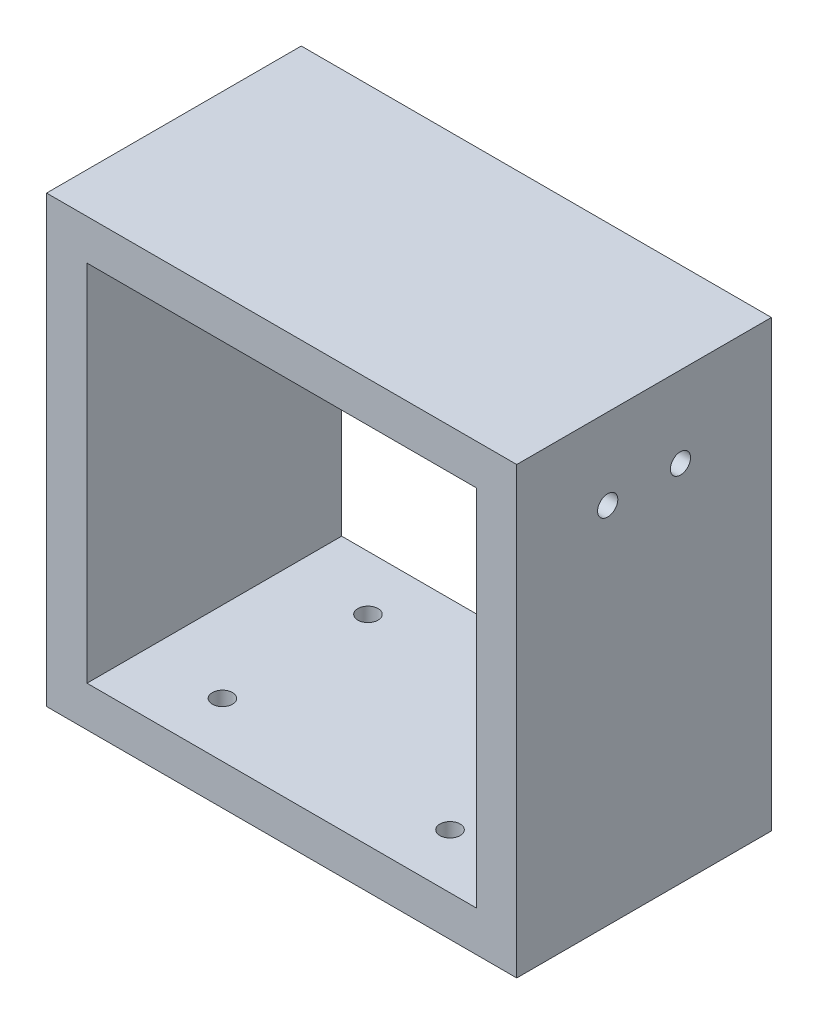
from build123d import *

# Parameters (mm, degrees)
SKETCH_1_W          = 58.15
SKETCH_1_H          = 31.5
EXTRUDE_1_DEPTH     = 55
SKETCH_2_W          = 48.15
SKETCH_2_H          = 45
CUT_EXTRUDE_1_DEPTH = 31.5
SKETCH_4_R          = 1.25
CUT_EXTRUDE_2_DEPTH = 10
SKETCH_5_R          = 1.25
CUT_EXTRUDE_3_DEPTH = 10
SKETCH_6_R          = 1.25
CUT_EXTRUDE_4_DEPTH = 10


with BuildPart() as part:
    # 草图1 → 凸台-拉伸1 (new body)
    with BuildSketch(Plane(origin=(0, 0, 0), x_dir=(1, 0, 0), z_dir=(0, 1, 0))):
        with Locations((29.075, 15.75)):
            Rectangle(SKETCH_1_W, SKETCH_1_H)
    extrude(amount=-EXTRUDE_1_DEPTH)

    # 草图2 → 切除-拉伸1 (cut)
    with BuildSketch(Plane.XY):
        with Locations((29.075, -27.5)):
            Rectangle(SKETCH_2_W, SKETCH_2_H)
    extrude(amount=-CUT_EXTRUDE_1_DEPTH, mode=Mode.SUBTRACT)

    # 草图4 → 切除-拉伸2 (cut)
    with BuildSketch(Plane.XZ.offset(55)):
        with Locations((15, -6.75)):
            Circle(SKETCH_4_R)
        with Locations((15, -24.75)):
            Circle(SKETCH_4_R)
        with Locations((43.15, -6.75)):
            Circle(SKETCH_4_R)
        with Locations((43.15, -24.75)):
            Circle(SKETCH_4_R)
    extrude(amount=-CUT_EXTRUDE_2_DEPTH, mode=Mode.SUBTRACT)

    # 草图5 → 切除-拉伸3 (cut)
    with BuildSketch(Plane.ZY.offset(-53.15)):
        with Locations((-20.25, -10)):
            Circle(SKETCH_5_R)
        with Locations((-11.25, -10)):
            Circle(SKETCH_5_R)
    extrude(amount=-CUT_EXTRUDE_3_DEPTH, mode=Mode.SUBTRACT)

    # 草图6 → 切除-拉伸4 (cut)
    with BuildSketch(Plane(origin=(5, 0, 0), x_dir=(0, 0, -1), z_dir=(1, 0, 0))):
        with Locations((11.25, -10)):
            Circle(SKETCH_6_R)
        with Locations((20.25, -10)):
            Circle(SKETCH_6_R)
    extrude(amount=-CUT_EXTRUDE_4_DEPTH, mode=Mode.SUBTRACT)


solid = part.part
